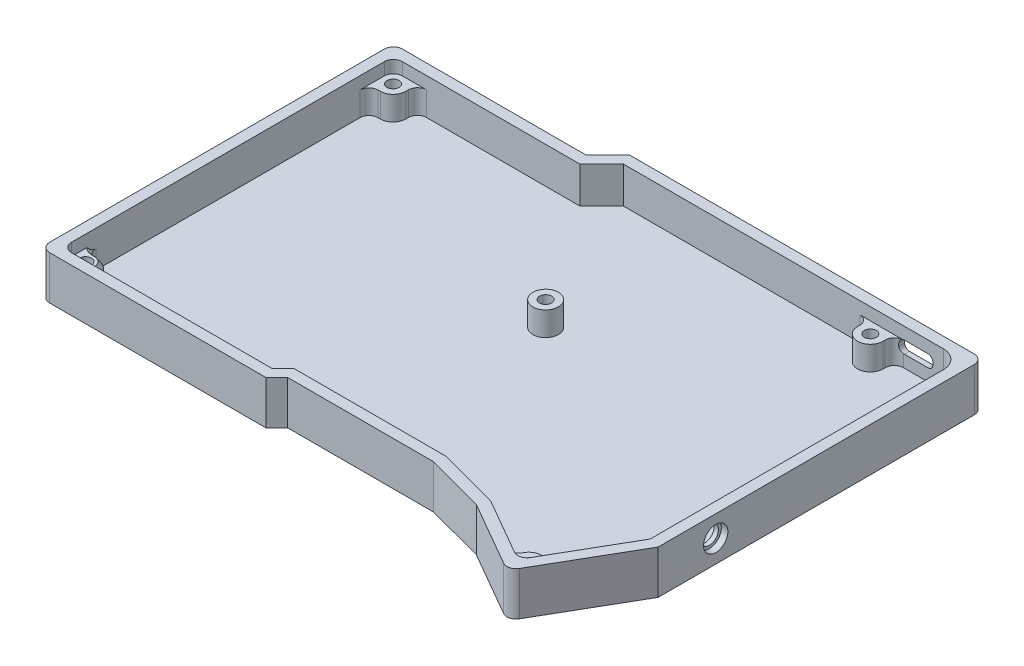
from build123d import *
from OCP.BRepFilletAPI import BRepFilletAPI_MakeChamfer

# Parameters (mm, degrees)
BOSS_EXTRUDE1_DEPTH = 10
BOSS_EXTRUDE2_DEPTH = 2
FILLET1_R           = 2.5
FILLET2_R           = 2.5
FILLET4_R           = 5
SKETCH3_R           = 3.5
BOSS_EXTRUDE3_DEPTH = 6.6
SKETCH5_R           = 1.65
CUT_EXTRUDE1_DEPTH  = 2.5
FILLET3_R           = 2.5
SKETCH6_R           = 2.55
CUT_EXTRUDE2_DEPTH  = 167.136549573
SKETCH7_R           = 3.35
CUT_EXTRUDE3_DEPTH  = 1.8
CUT_EXTRUDE4_REACH  = 141.279
SKETCH8_W           = 9.14
SKETCH8_H           = 3.36
FILLET5_R           = 1.3
CUT_EXTRUDE5_DEPTH  = 1.6
CHAMFER1_SIZE       = 1.5
CHAMFER1_SIZE2      = 1.050311307


with BuildPart() as part:
    # Sketch1 → Boss-Extrude1 (new body)
    with BuildSketch(Plane(origin=(0, 0, 0), x_dir=(1, 0, 0), z_dir=(0, 1, 0))):
        Polygon((78.125, -37.9381301), (62.908489388, -64.283910205), (42.956179643, -52.779359478), (26.916138362, -48.5), (-13.175252532, -48.5), (-16.175252532, -51.5), (-78.125, -51.5), (-78.125, 45.5), (-25.074747468, 45.5), (-19.074747468, 51.5), (78.125, 51.5), align=None)
        Polygon((75.125, -37.134018586), (61.80999823, -60.187537075), (44.11188212, -49.982759925), (27.309448337, -45.5), (-14.417893219, -45.5), (-17.417893219, -48.5), (-75.125, -48.5), (-75.125, 42.5), (-23.832106781, 42.5), (-17.832106781, 48.5), (75.125, 48.5), align=None, mode=Mode.SUBTRACT)
    extrude(amount=BOSS_EXTRUDE1_DEPTH)

    # Sketch2 → Boss-Extrude2 (add)
    with BuildSketch(Plane.XZ):
        Polygon((78.125, -51.5), (78.125, 37.9381301), (62.908489388, 64.283910205), (42.956179643, 52.779359478), (26.916138362, 48.5), (-13.175252532, 48.5), (-16.175252532, 51.5), (-78.125, 51.5), (-78.125, -45.5), (-25.074747468, -45.5), (-19.074747468, -51.5), align=None)
    extrude(amount=BOSS_EXTRUDE2_DEPTH)

    # Fillet1
    fillet1_edges = [part.edges().sort_by_distance(p)[0] for p in [
        (-75.125, 5, -42.5),
        (-75.125, 5, 48.5),
        (61.80999823, 5, 60.187537075),
    ]]
    fillet(fillet1_edges, radius=FILLET1_R)

    # Fillet2
    fillet2_edges = [part.edges().sort_by_distance(p)[0] for p in [
        (62.908489388, 4, 64.283910205),
        (-78.125, 4, 51.5),
        (-78.125, 4, -45.5),
        (78.125, 4, -51.5),
    ]]
    fillet(fillet2_edges, radius=FILLET2_R)

    # Fillet4
    fillet4_edges = [part.edges().sort_by_distance(p)[0] for p in [
        (75.125, 5, -48.5),
    ]]
    fillet(fillet4_edges, radius=FILLET4_R)

    # Sketch3 → Boss-Extrude3 (add)
    with BuildSketch(Plane(origin=(0, 0, 0), x_dir=(1, 0, 0), z_dir=(0, 1, 0))):
        with BuildLine():
            ThreePointArc((-68.5, -45.3), (-69.525126266, -42.825126266), (-72, -41.8))
            ThreePointArc((-72, -41.8), (-73.834848074, -42.319508003), (-75.125, -43.723809973))
            Line((-75.125, -43.723809973), (-75.125, -46))
            ThreePointArc((-75.125, -46), (-74.392766953, -47.767766953), (-72.625, -48.5))
            Line((-72.625, -48.5), (-70.582255312, -48.5))
            ThreePointArc((-70.582255312, -48.5), (-69.066392459, -47.208912464), (-68.5, -45.3))
        make_face()
        with BuildLine():
            Line((-75.125, -46), (-75.125, -43.723809973))
            ThreePointArc((-75.125, -43.723809973), (-74.536075308, -47.712119821), (-70.582255312, -48.5))
            Line((-70.582255312, -48.5), (-72.625, -48.5))
            ThreePointArc((-72.625, -48.5), (-74.392766953, -47.767766953), (-75.125, -46))
        make_face()
        with BuildLine():
            Line((-72, -41.8), (-75.125, -41.8))
            Line((-75.125, -41.8), (-75.125, -43.723809973))
            ThreePointArc((-75.125, -43.723809973), (-73.834848074, -42.319508003), (-72, -41.8))
        make_face()
        with BuildLine():
            ThreePointArc((-70.582255312, 42.5), (-69.066392459, 41.208912464), (-68.5, 39.3))
            Line((-68.5, 39.3), (-68.5, 42.5))
            Line((-68.5, 42.5), (-70.582255312, 42.5))
        make_face()
        with BuildLine():
            ThreePointArc((-72, 35.8), (-69.525126266, 36.825126266), (-68.5, 39.3))
            ThreePointArc((-68.5, 39.3), (-69.066392459, 41.208912464), (-70.582255312, 42.5))
            Line((-70.582255312, 42.5), (-72.625, 42.5))
            ThreePointArc((-72.625, 42.5), (-74.392766953, 41.767766953), (-75.125, 40))
            Line((-75.125, 40), (-75.125, 37.723809973))
            ThreePointArc((-75.125, 37.723809973), (-73.834848074, 36.319508003), (-72, 35.8))
        make_face()
        with BuildLine():
            Line((-72.625, 42.5), (-70.582255312, 42.5))
            ThreePointArc((-70.582255312, 42.5), (-74.536075308, 41.712119821), (-75.125, 37.723809973))
            Line((-75.125, 37.723809973), (-75.125, 40))
            ThreePointArc((-75.125, 40), (-74.392766953, 41.767766953), (-72.625, 42.5))
        make_face()
        with BuildLine():
            Line((-75.125, 35.8), (-72, 35.8))
            ThreePointArc((-72, 35.8), (-73.834848074, 36.319508003), (-75.125, 37.723809973))
            Line((-75.125, 37.723809973), (-75.125, 35.8))
        make_face()
        with Locations(Location((0.325, 8.92, 0), (0, 0, 90))):
            Circle(SKETCH3_R)
        with BuildLine():
            ThreePointArc((54.769807681, 48.5), (53.145, 48.9), (51.520192319, 48.5))
            Line((51.520192319, 48.5), (54.769807681, 48.5))
        make_face()
        with BuildLine():
            Line((54.769807681, 48.5), (51.520192319, 48.5))
            ThreePointArc((51.520192319, 48.5), (50.150269054, 47.21151499), (49.645, 45.4))
            ThreePointArc((49.645, 45.4), (53.145, 41.9), (56.645, 45.4))
            ThreePointArc((56.645, 45.4), (56.139730946, 47.21151499), (54.769807681, 48.5))
        make_face()
        with BuildLine():
            Line((56.645, 48.5), (54.769807681, 48.5))
            ThreePointArc((54.769807681, 48.5), (56.139730946, 47.21151499), (56.645, 45.4))
            Line((56.645, 45.4), (56.645, 48.5))
        make_face()
        with BuildLine():
            Line((51.520192319, 48.5), (49.645, 48.5))
            Line((49.645, 48.5), (49.645, 45.4))
            ThreePointArc((49.645, 45.4), (50.150269054, 47.21151499), (51.520192319, 48.5))
        make_face()
        with BuildLine():
            Line((65.06794725, -54.546742633), (62.39329915, -53.001948322))
            ThreePointArc((62.39329915, -53.001948322), (63.67559788, -54.283168367), (64.145, -56.034018586))
            ThreePointArc((64.145, -56.034018586), (64.144536351, -56.090986384), (64.143145526, -56.14793909))
            Line((64.143145526, -56.14793909), (65.06794725, -54.546742633))
        make_face()
        with BuildLine():
            ThreePointArc((64.145, -56.034018586), (63.67559788, -54.283168367), (62.39329915, -53.001948322))
            ThreePointArc((62.39329915, -53.001948322), (59.73723674, -52.653786957), (57.612929736, -54.285719436))
            ThreePointArc((57.612929736, -54.285719436), (57.145023166, -56.02128423), (57.600288117, -57.760207901))
            Line((57.600288117, -57.760207901), (59.645803824, -58.939657274))
            ThreePointArc((59.645803824, -58.939657274), (61.542115723, -59.188578919), (63.059447202, -58.024248216))
            Line((63.059447202, -58.024248216), (64.143145526, -56.14793909))
            ThreePointArc((64.143145526, -56.14793909), (64.144536351, -56.090986384), (64.145, -56.034018586))
        make_face()
        with BuildLine():
            ThreePointArc((57.600288117, -57.760207901), (61.48240862, -59.432363301), (64.143145526, -56.14793909))
            Line((64.143145526, -56.14793909), (63.059447202, -58.024248216))
            ThreePointArc((63.059447202, -58.024248216), (61.542115723, -59.188578919), (59.645803824, -58.939657274))
            Line((59.645803824, -58.939657274), (57.600288117, -57.760207901))
        make_face()
        with BuildLine():
            Line((57.612929736, -54.285719436), (56.106253452, -56.898743849))
            Line((56.106253452, -56.898743849), (57.600288117, -57.760207901))
            ThreePointArc((57.600288117, -57.760207901), (57.145023166, -56.02128423), (57.612929736, -54.285719436))
        make_face()
        with BuildLine():
            Line((-68.5, -48.5), (-68.5, -45.3))
            ThreePointArc((-68.5, -45.3), (-69.066392459, -47.208912464), (-70.582255312, -48.5))
            Line((-70.582255312, -48.5), (-68.5, -48.5))
        make_face()
    extrude(amount=BOSS_EXTRUDE3_DEPTH)

    # Sketch5 → Cut-Extrude1 (cut)
    with BuildSketch(Plane(origin=(0, 6.6, 0), x_dir=(1, 0, 0), z_dir=(0, 1, 0))):
        with Locations(Location((-72, 39.3, 0), (0, 0, 270))):
            Circle(SKETCH5_R)
        with Locations(Location((0.325, 8.92, 0), (0, 0, 270))):
            Circle(SKETCH5_R)
        with Locations(Location((53.145, 45.4, 0), (0, 0, 270))):
            Circle(SKETCH5_R)
        with Locations(Location((60.645, -56.034018586, 0), (0, 0, 270))):
            Circle(SKETCH5_R)
        with Locations(Location((-72, -45.3, 0), (0, 0, 270))):
            Circle(SKETCH5_R)
    extrude(amount=-CUT_EXTRUDE1_DEPTH, mode=Mode.SUBTRACT)

    # Fillet3
    fillet3_edges = [part.edges().sort_by_distance(p)[0] for p in [
        (-68.5, 3.3, -42.5),
        (-75.125, 3.3, -35.8),
        (56.645, 3.3, -48.5),
        (49.645, 3.3, -48.5),
        (65.06794725, 3.3, 54.546742633),
        (56.106253452, 3.3, 56.898743849),
        (-68.5, 3.3, 48.5),
        (-75.125, 3.3, 41.8),
    ]]
    fillet(fillet3_edges, radius=FILLET3_R)

    # Sketch6 → Cut-Extrude2 (cut, through all)
    with BuildSketch(Plane.ZY.offset(-75.125)):
        with Locations((22.099069046, 4.1)):
            Circle(SKETCH6_R)
    extrude(amount=-CUT_EXTRUDE2_DEPTH, mode=Mode.SUBTRACT)

    # Sketch7 → Cut-Extrude3 (cut)
    with BuildSketch(Plane(origin=(78.125, 0, 0), x_dir=(0, 0, -1), z_dir=(1, 0, 0))):
        with Locations((-22.099069046, 4.1)):
            Circle(SKETCH7_R)
    extrude(amount=-CUT_EXTRUDE3_DEPTH, mode=Mode.SUBTRACT)

    # Sketch8 → Cut-Extrude4 (cut, up to next)
    with BuildSketch(Plane(origin=(0, 0, -51.5), x_dir=(-1, 0, 0), z_dir=(0, 0, -1)), mode=Mode.PRIVATE) as cut_extrude4_sk1:
        with Locations((-62.66, 5.02)):
            Rectangle(SKETCH8_W, SKETCH8_H)
    cut_extrude4_tool1 = extrude(cut_extrude4_sk1.sketch, amount=-CUT_EXTRUDE4_REACH, mode=Mode.PRIVATE) & part.part
    add(cut_extrude4_tool1.solids().sort_by_distance((62.66, 5.02, -51.5))[0], mode=Mode.SUBTRACT)

    # Fillet5
    fillet5_edges = [part.edges().sort_by_distance(p)[0] for p in [
        (67.23, 3.34, -50),
        (58.09, 3.34, -49.883244788),
        (58.09, 6.7, -50),
        (67.23, 6.7, -50),
    ]]
    fillet(fillet5_edges, radius=FILLET5_R)

    # Sketch9 → Cut-Extrude5 (cut)
    with BuildSketch(Plane(origin=(0, 0, -51.5), x_dir=(-1, 0, 0), z_dir=(0, 0, -1))):
        with BuildLine():
            Line((-69.73, 5.4), (-69.73, 4.64))
            ThreePointArc((-69.73, 4.64), (-68.617005769, 1.952994231), (-65.93, 0.84))
            Line((-65.93, 0.84), (-59.39, 0.84))
            ThreePointArc((-59.39, 0.84), (-56.702994231, 1.952994231), (-55.59, 4.64))
            Line((-55.59, 4.64), (-55.59, 5.4))
            ThreePointArc((-55.59, 5.4), (-56.702994231, 8.087005769), (-59.39, 9.2))
            Line((-59.39, 9.2), (-65.93, 9.2))
            ThreePointArc((-65.93, 9.2), (-68.617005769, 8.087005769), (-69.73, 5.4))
        make_face()
    extrude(amount=-CUT_EXTRUDE5_DEPTH, mode=Mode.SUBTRACT)

    # Chamfer1: one chamfer whose edges measure the first distance from different faces: ONE call of the kernel's chamfer builder (chamfer() names one face for all edges)
    chamfer1_edges_1 = [part.edges().sort_by_distance(p)[0] for p in [
        (-68.5, 6.6, 45.65),
    ]]
    chamfer1_side_1 = [part.faces().sort_by_distance(p)[0] for p in [
        (-68.5, 3.3, 45.65),
    ]]
    chamfer1_edges_2 = [part.edges().sort_by_distance(p)[0] for p in [
        (-69.525126266, 6.6, 42.825126266),
    ]]
    chamfer1_side_2 = [part.faces().sort_by_distance(p)[0] for p in [
        (-69.525126266, 3.3, 42.825126266),
    ]]
    chamfer1_edges_3 = [part.edges().sort_by_distance(p)[0] for p in [
        (-72.3125, 6.6, 41.8),
    ]]
    chamfer1_side_3 = [part.faces().sort_by_distance(p)[0] for p in [
        (-72.3125, 3.3, 41.8),
    ]]
    chamfer1_edges_4 = [part.edges().sort_by_distance(p)[0] for p in [
        (-67.767766953, 6.6, 47.767766953),
    ]]
    chamfer1_side_4 = [part.faces().sort_by_distance(p)[0] for p in [
        (-67.767766953, 3.3, 47.767766953),
    ]]
    chamfer1_edges_5 = [part.edges().sort_by_distance(p)[0] for p in [
        (-74.392766953, 6.6, 41.067766953),
    ]]
    chamfer1_side_5 = [part.faces().sort_by_distance(p)[0] for p in [
        (-74.392766953, 3.3, 41.067766953),
    ]]
    chamfer1 = BRepFilletAPI_MakeChamfer(part.part.solid().wrapped)
    for e in chamfer1_edges_1:
        chamfer1.Add(CHAMFER1_SIZE, CHAMFER1_SIZE2, e.wrapped, chamfer1_side_1[0].wrapped)  # the first distance lies on this face
    for e in chamfer1_edges_2:
        chamfer1.Add(CHAMFER1_SIZE, CHAMFER1_SIZE2, e.wrapped, chamfer1_side_2[0].wrapped)  # the first distance lies on this face
    for e in chamfer1_edges_3:
        chamfer1.Add(CHAMFER1_SIZE, CHAMFER1_SIZE2, e.wrapped, chamfer1_side_3[0].wrapped)  # the first distance lies on this face
    for e in chamfer1_edges_4:
        chamfer1.Add(CHAMFER1_SIZE, CHAMFER1_SIZE2, e.wrapped, chamfer1_side_4[0].wrapped)  # the first distance lies on this face
    for e in chamfer1_edges_5:
        chamfer1.Add(CHAMFER1_SIZE, CHAMFER1_SIZE2, e.wrapped, chamfer1_side_5[0].wrapped)  # the first distance lies on this face
    add(Compound.cast(chamfer1.Shape()), mode=Mode.REPLACE)


solid = part.part
